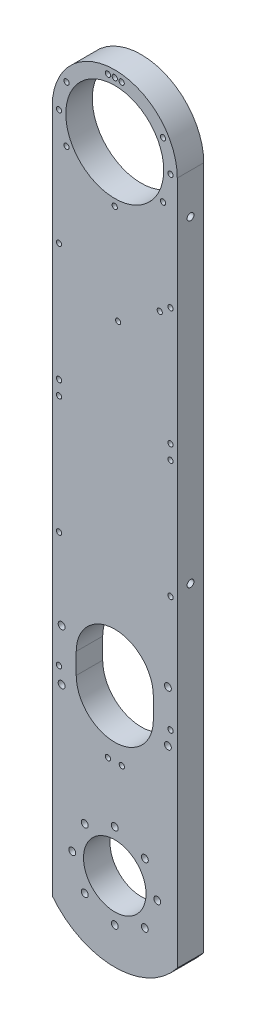
from build123d import *

# Parameters (mm, degrees)
BOSS_EXTRUDE1_DEPTH              = 12.7
CUT_EXTRUDE1_DEPTH               = 13.7
HOLE1_D                          = 30
HOLE1_DEPTH                      = 12.7
HOLE2_D                          = 47
HOLE2_DEPTH                      = 12.7
F_39_0_0995_DIAMETER_HOLE1_D     = 2.5273
F_39_0_0995_DIAMETER_HOLE1_DEPTH = 12.7
F_4_CLEARANCE_HOLE1_D            = 3.3
F_4_CLEARANCE_HOLE1_DEPTH        = 12.7
F_2_CLEARANCE_HOLE1_D            = 2.499999999
F_2_CLEARANCE_HOLE1_DEPTH        = 12.7
F_4_CLEARANCE_HOLE2_D            = 3.3
F_4_CLEARANCE_HOLE2_DEPTH        = 10


with BuildPart() as part:
    # Sketch1 → Boss-Extrude1 (new body)
    with BuildSketch(Plane.XY.offset(12.7)):
        with BuildLine():
            Line((-30, 305), (-30, 23.323807579))
            Line((-30, 23.323807579), (-30, -23.323807579))
            ThreePointArc((-30, -23.323807579), (0, -38), (30, -23.323807579))
            Line((30, -23.323807579), (30, 23.323807579))
            Line((30, 23.323807579), (30, 305))
            ThreePointArc((30, 305), (0, 335), (-30, 305))
        make_face()
    extrude(amount=-BOSS_EXTRUDE1_DEPTH)

    # Sketch2 → Cut-Extrude1 (cut, through all)
    with BuildSketch(Plane(origin=(0, 0, 0), x_dir=(-1, 0, 0), z_dir=(0, 0, -1))):
        with BuildLine():
            Line((18.5, 74.022471071), (18.5, 84.022471071))
            ThreePointArc((18.5, 84.022471071), (0, 102.522471071), (-18.5, 84.022471071))
            Line((-18.5, 84.022471071), (-18.5, 74.022471071))
            ThreePointArc((-18.5, 74.022471071), (0, 55.522471071), (18.5, 74.022471071))
        make_face()
    extrude(amount=-CUT_EXTRUDE1_DEPTH, mode=Mode.SUBTRACT)

    # Hole1
    with Locations(Plane.XY.offset(12.7)):
        with Locations((0, 0)):
            Hole(HOLE1_D / 2, depth=HOLE1_DEPTH)

    # Hole2
    with Locations(Plane.XY.offset(12.7)):
        with Locations((0, 305)):
            Hole(HOLE2_D / 2, depth=HOLE2_DEPTH)

    # #39 (0.0995) Diameter Hole1
    with Locations(Plane.XY.offset(12.7)):
        with Locations((-26.75, 74.022471071), (-26.75, 129.511235535), (-26.75, 186.111235535), (-26.750000001, 192.911235535), (-26.750000001, 249.511235535), (-26.750000001, 305), (-3.300000001, 331.545668196), (3.299999999, 331.545668196), (26.749999999, 305), (26.749999999, 249.511235535), (26.749999999, 192.911235535), (26.75, 186.111235535), (26.75, 129.511235535), (26.75, 74.022471071), (3.4, 47.489425637), (-3.3, 47.476802874), (-23.166179551, 318.375), (-23.166179551, 291.625), (0, 278.25), (23.166179551, 291.625), (23.166179551, 318.375), (0, 331.75)):
            Hole(F_39_0_0995_DIAMETER_HOLE1_D / 2, depth=F_39_0_0995_DIAMETER_HOLE1_DEPTH)

    # #4 Clearance Hole1
    with Locations(Plane(origin=(0, 0, 0), x_dir=(-1, 0, 0), z_dir=(0, 0, -1))):
        with Locations((-25.5016, 66.772471071), (-25.5016, 91.272471071), (14.424978336, 14.424978336), (20.4, 0), (14.424978336, -14.424978336), (0, -20.4), (-14.424978336, -14.424978336), (-20.4, 0), (-14.424978336, 14.424978336), (0, 20.4), (25.5016, 66.772471071), (25.5016, 91.272471071)):
            Hole(F_4_CLEARANCE_HOLE1_D / 2, depth=F_4_CLEARANCE_HOLE1_DEPTH)

    # #2 Clearance Hole1
    with Locations(Plane(origin=(0, 0, 0), x_dir=(-1, 0, 0), z_dir=(0, 0, -1))):
        with Locations((-1.619921459, 231.265288591), (-21.578861519, 245.43367635)):
            Hole(F_2_CLEARANCE_HOLE1_D / 2, depth=F_2_CLEARANCE_HOLE1_DEPTH)

    # #4 Clearance Hole2
    with Locations(Plane(origin=(30, 0, 0), x_dir=(0, 0, -1), z_dir=(1, 0, 0))):
        with Locations((-6.35, 285.723807579), (-6.35, 133.323807579)):
            Hole(F_4_CLEARANCE_HOLE2_D / 2, depth=F_4_CLEARANCE_HOLE2_DEPTH)


solid = part.part
